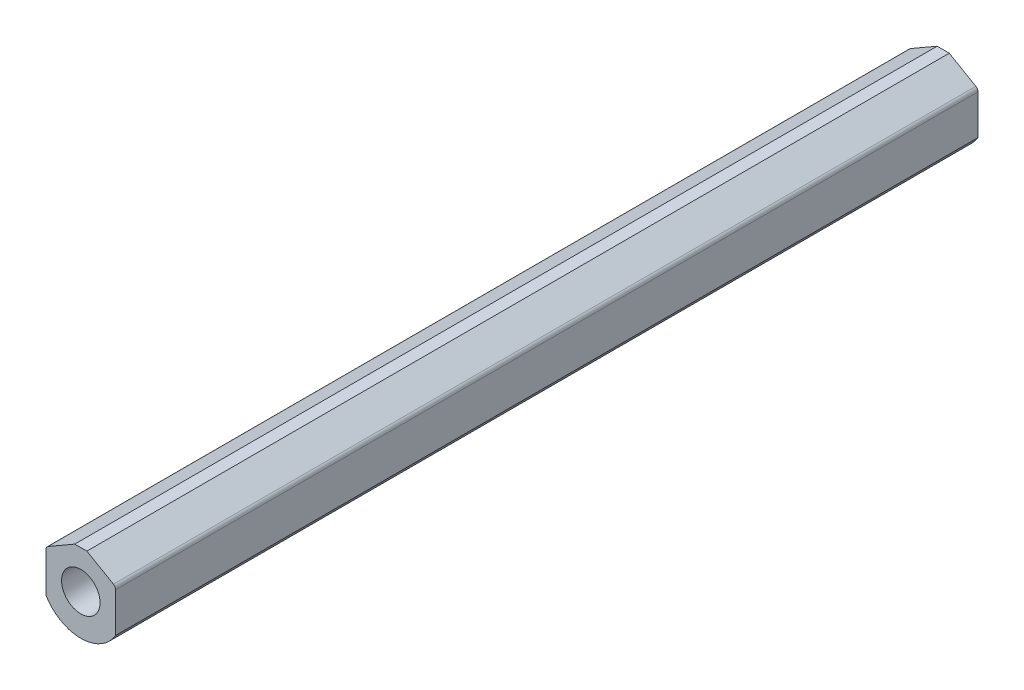
from build123d import *

# Parameters (mm, degrees)
SKETCH1_R      = 13.6144
EXTRUDE1_DEPTH = 609.6


with BuildPart() as part:
    # Sketch1 → Extrude1 (new body)
    with BuildSketch(Plane.XY):
        with BuildLine():
            Line((-4.287037938, 26.9748), (4.287037938, 26.9748))
            Line((4.287037938, 26.9748), (23.0759, 16.127045431))
            ThreePointArc((23.0759, 16.127045431), (24.191545431, 15.0114), (24.5999, 13.4874))
            Line((24.5999, 13.4874), (24.5999, -14.538760091))
            ThreePointArc((24.5999, -14.538760091), (0, -28.575), (-24.5999, -14.538760091))
            Line((-24.5999, -14.538760091), (-24.5999, 13.4874))
            ThreePointArc((-24.5999, 13.4874), (-24.191545431, 15.0114), (-23.0759, 16.127045431))
            Line((-23.0759, 16.127045431), (-4.287037938, 26.9748))
        make_face()
        Circle(SKETCH1_R, mode=Mode.SUBTRACT)
    extrude(amount=-EXTRUDE1_DEPTH)


solid = part.part
